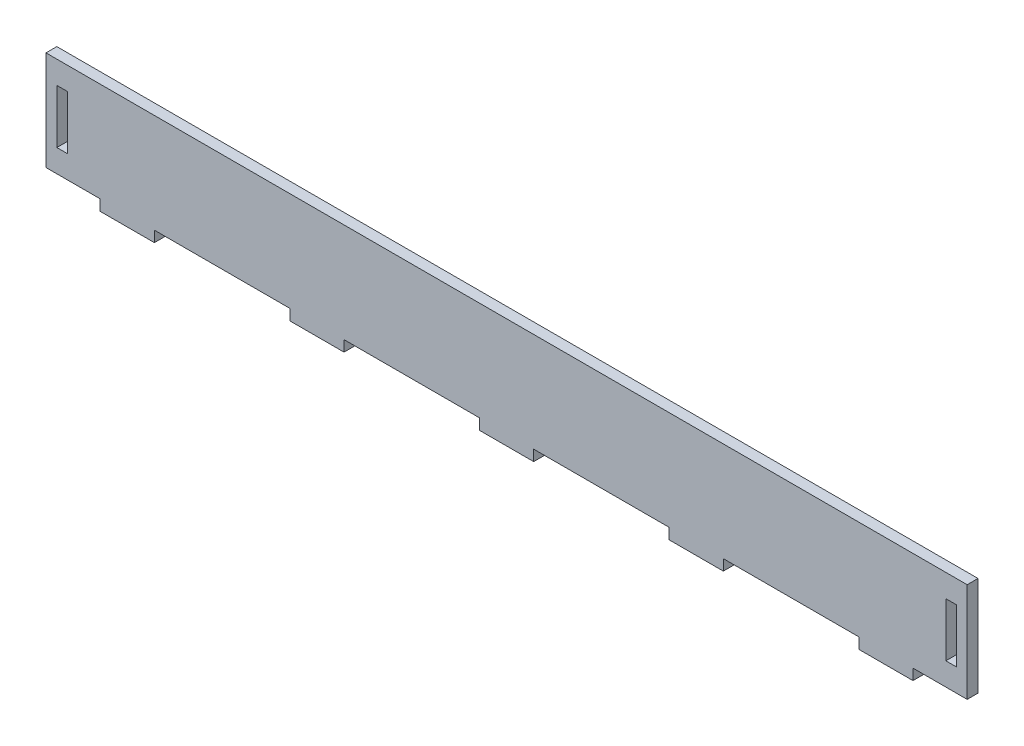
from build123d import *

# Parameters (mm, degrees)
CROQUIS1_W              = 510
CROQUIS1_H              = 55
SALIENTE_EXTRUIR1_DEPTH = 6
CORTAR_EXTRUIR1_REACH   = 8
CROQUIS2_W              = 5.8
CROQUIS2_H              = 29.8
CROQUIS3_W              = 30
CROQUIS3_H              = 6
SALIENTE_EXTRUIR2_DEPTH = 6


with BuildPart() as part:
    # Croquis1 → Saliente-Extruir1 (new body)
    with BuildSketch(Plane.XY):
        Rectangle(CROQUIS1_W, CROQUIS1_H)
    extrude(amount=SALIENTE_EXTRUIR1_DEPTH)

    # Croquis2 → Cortar-Extruir1 (cut, up to next)
    with BuildSketch(Plane.XY.offset(6), mode=Mode.PRIVATE) as cortar_extruir1_sk1:
        with Locations((-246.1, 0)):
            Rectangle(CROQUIS2_W, CROQUIS2_H)
    cortar_extruir1_tool1 = extrude(cortar_extruir1_sk1.sketch, amount=-CORTAR_EXTRUIR1_REACH, mode=Mode.PRIVATE) & part.part
    add(cortar_extruir1_tool1.solids().sort_by_distance((-246.1, 0, 6))[0], mode=Mode.SUBTRACT)
    # Croquis2 → Cortar-Extruir1 (cut, up to next)
    with BuildSketch(Plane.XY.offset(6), mode=Mode.PRIVATE) as cortar_extruir1_sk2:
        with Locations((246.1, 0)):
            Rectangle(CROQUIS2_W, CROQUIS2_H)
    cortar_extruir1_tool2 = extrude(cortar_extruir1_sk2.sketch, amount=-CORTAR_EXTRUIR1_REACH, mode=Mode.PRIVATE) & part.part
    add(cortar_extruir1_tool2.solids().sort_by_distance((246.1, 0, 6))[0], mode=Mode.SUBTRACT)

    # Croquis3 → Saliente-Extruir2 (add)
    with BuildSketch(Plane.XZ.offset(27.5)):
        with Locations((0, 3)):
            Rectangle(CROQUIS3_W, CROQUIS3_H)
        with Locations((105, 3)):
            Rectangle(CROQUIS3_W, CROQUIS3_H)
        with Locations((210, 3)):
            Rectangle(CROQUIS3_W, CROQUIS3_H)
        with Locations((-105, 3)):
            Rectangle(CROQUIS3_W, CROQUIS3_H)
        with Locations((-210, 3)):
            Rectangle(CROQUIS3_W, CROQUIS3_H)
    extrude(amount=SALIENTE_EXTRUIR2_DEPTH)


solid = part.part
